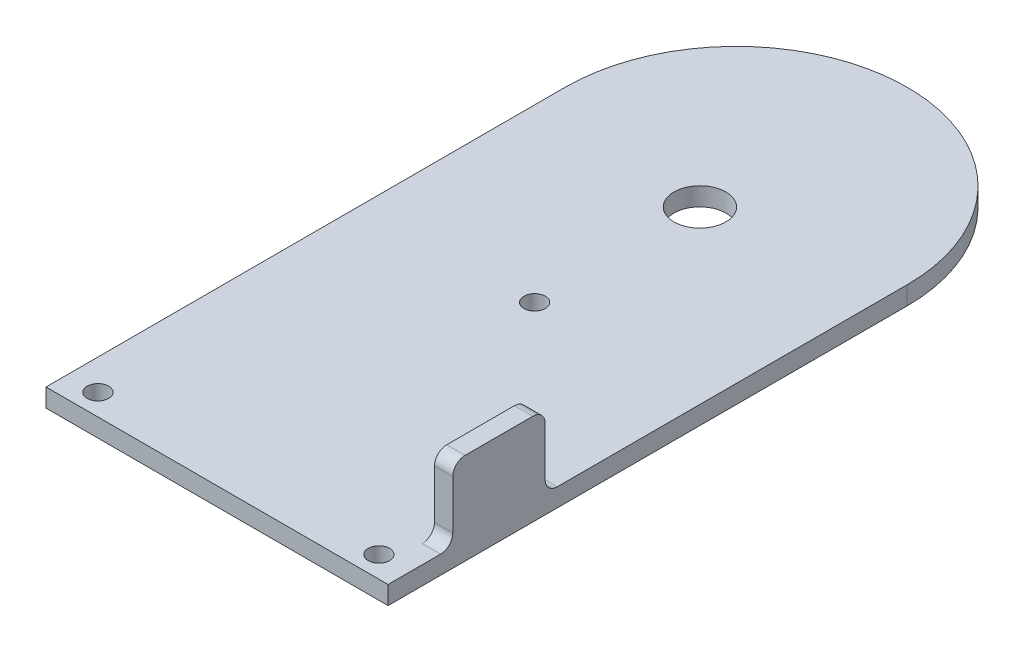
from build123d import *

# Parameters (mm, degrees)
SKETCH1_R           = 1.75
SKETCH1_R_2         = 4.25
BOSS_EXTRUDE1_DEPTH = 3
SKETCH2_W           = 3
SKETCH2_H           = 15.115775603
BOSS_EXTRUDE2_DEPTH = 12
FILLET1_R           = 2


with BuildPart() as part:
    # Sketch1 → Boss-Extrude1 (new body)
    with BuildSketch(Plane(origin=(0, 0, 0), x_dir=(1, 0, 0), z_dir=(0, 1, 0))):
        with BuildLine():
            Line((0, 0), (0, -85))
            Line((0, -85), (56, -85))
            Line((56, -85), (56, 6.6e-08))
            ThreePointArc((56, 6.6e-08), (27.999999967, 28.000000033), (0, 0))
        make_face()
        with Locations((5, -81.5)):
            Circle(SKETCH1_R, mode=Mode.SUBTRACT)
        with Locations((51, -81.5)):
            Circle(SKETCH1_R, mode=Mode.SUBTRACT)
        with Locations((28, -33)):
            Circle(SKETCH1_R, mode=Mode.SUBTRACT)
        with Locations((28, -5.94)):
            Circle(SKETCH1_R_2, mode=Mode.SUBTRACT)
    extrude(amount=BOSS_EXTRUDE1_DEPTH)

    # Sketch2 → Boss-Extrude2 (add)
    with BuildSketch(Plane(origin=(0, 3, 0), x_dir=(1, 0, 0), z_dir=(0, 1, 0))):
        with Locations((54.5, -66.844146369)):
            Rectangle(SKETCH2_W, SKETCH2_H)
    extrude(amount=BOSS_EXTRUDE2_DEPTH)

    # Fillet1
    fillet1_edges = [part.edges().sort_by_distance(p)[0] for p in [
        (54.5, 3, 59.286258567),
        (54.5, 3, 74.40203417),
        (54.5, 15, 59.286258567),
        (54.5, 15, 74.40203417),
    ]]
    fillet(fillet1_edges, radius=FILLET1_R)


solid = part.part
